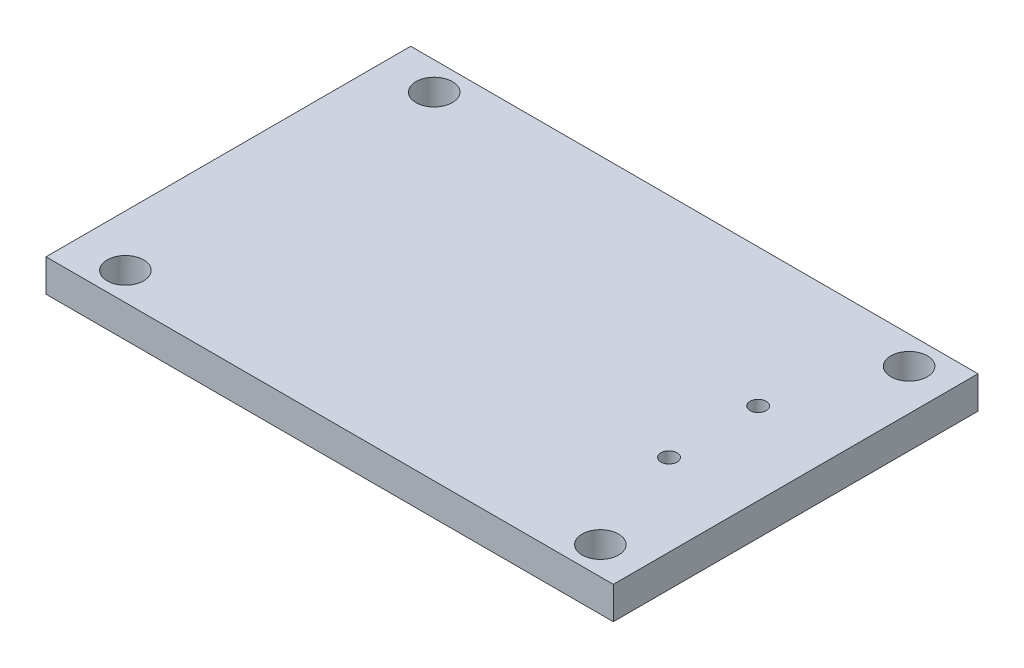
from build123d import *

# Parameters (mm, degrees)
SKETCH1_W           = 28
SKETCH1_H           = 18
BOSS_EXTRUDE2_DEPTH = 1.6
SKETCH4_R           = 0.9
CUT_EXTRUDE5_DEPTH  = 1.6
SKETCH9_R           = 0.4
CUT_EXTRUDE6_DEPTH  = 10


with BuildPart() as part:
    # Sketch1 → Boss-Extrude2 (new body)
    with BuildSketch(Plane(origin=(0, 0, 0), x_dir=(1, 0, 0), z_dir=(0, 1, 0))):
        with Locations((17.78, 7.62)):
            Rectangle(SKETCH1_W, SKETCH1_H)
    extrude(amount=BOSS_EXTRUDE2_DEPTH)

    # Sketch4 → Cut-Extrude5 (cut)
    with BuildSketch(Plane(origin=(0, 0, 0), x_dir=(1, 0, 0), z_dir=(0, 1, 0))):
        with Locations((29.76, 15.24)):
            Circle(SKETCH4_R)
        with Locations((29.76, 0)):
            Circle(SKETCH4_R)
        with Locations((6.32, 0)):
            Circle(SKETCH4_R)
        with Locations((6.32, 15.24)):
            Circle(SKETCH4_R)
    extrude(amount=CUT_EXTRUDE5_DEPTH, mode=Mode.SUBTRACT)

    # Sketch9 → Cut-Extrude6 (cut)
    with BuildSketch(Plane(origin=(0, 0, 0), x_dir=(1, 0, 0), z_dir=(0, 1, 0))):
        with Locations((27.73, 5.42)):
            Circle(SKETCH9_R)
        with Locations((27.73, 9.82)):
            Circle(SKETCH9_R)
    extrude(amount=CUT_EXTRUDE6_DEPTH, mode=Mode.SUBTRACT)


solid = part.part
